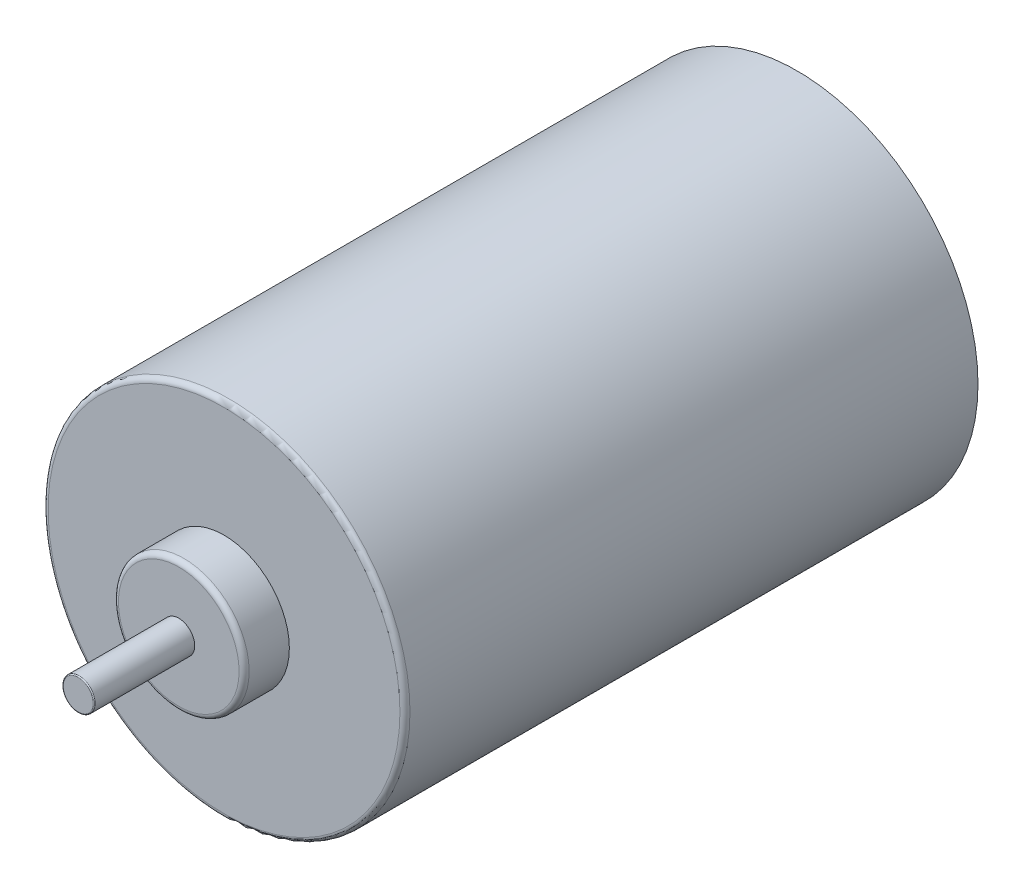
from build123d import *

# Parameters (mm, degrees)
SKETCH1_R                = 18
SKETCH1_R_2              = 17
BOSS_EXTRUDE1_DEPTH      = 57
SKETCH4_R                = 18
BOSS_EXTRUDE4_DEPTH      = 2
SKETCH5_R                = 13
BOSS_EXTRUDE5_DEPTH      = 2
SKETCH6_R                = 1.5875
CUT_EXTRUDE1_DEPTH       = 4
SKETCH7_R                = 18
BOSS_EXTRUDE6_DEPTH      = 1
SKETCH8_R                = 6.5
BOSS_EXTRUDE7_DEPTH      = 4.5
SKETCH9_R                = 1.5875
CUT_EXTRUDE4_DEPTH       = 64.5
SKETCH10_R               = 1.5875
BOSS_EXTRUDE8_DEPTH      = 10
BOSS_EXTRUDE8_DEPTH_BACK = 65
FILLET1_R                = 0.5
FILLET2_R                = 0.1
CHAMFER1_SIZE            = 1
FILLET3_R                = 0.1


with BuildPart() as part:
    # Sketch1 → Boss-Extrude1 (new body)
    with BuildSketch(Plane.XY):
        Circle(SKETCH1_R)
        Circle(SKETCH1_R_2, mode=Mode.SUBTRACT)
    extrude(amount=BOSS_EXTRUDE1_DEPTH)

    # Sketch4 → Boss-Extrude4 (add)
    with BuildSketch(Plane(origin=(0, 0, 0), x_dir=(-1, 0, 0), z_dir=(0, 0, -1))):
        Circle(SKETCH4_R)
    extrude(amount=-BOSS_EXTRUDE4_DEPTH)

    # Sketch5 → Boss-Extrude5 (add)
    with BuildSketch(Plane(origin=(0, 0, 0), x_dir=(-1, 0, 0), z_dir=(0, 0, -1))):
        Circle(SKETCH5_R)
    extrude(amount=BOSS_EXTRUDE5_DEPTH)

    # Sketch6 → Cut-Extrude1 (cut)
    with BuildSketch(Plane(origin=(0, 0, -2), x_dir=(-1, 0, 0), z_dir=(0, 0, -1))):
        Circle(SKETCH6_R)
    extrude(amount=-CUT_EXTRUDE1_DEPTH, mode=Mode.SUBTRACT)

    # Sketch7 → Boss-Extrude6 (add)
    with BuildSketch(Plane.XY.offset(57)):
        Circle(SKETCH7_R)
    extrude(amount=-BOSS_EXTRUDE6_DEPTH)

    # Sketch8 → Boss-Extrude7 (add)
    with BuildSketch(Plane.XY.offset(57)):
        Circle(SKETCH8_R)
    extrude(amount=BOSS_EXTRUDE7_DEPTH)

    # Sketch9 → Cut-Extrude4 (cut, through all)
    with BuildSketch(Plane.XY.offset(61.5)):
        Circle(SKETCH9_R)
    extrude(amount=-CUT_EXTRUDE4_DEPTH, mode=Mode.SUBTRACT)

    # Fillet1
    fillet1_edges = [part.edges().sort_by_distance(p)[0] for p in [
        (-6.5, 0, 61.5),
        (-18, 0, 57),
    ]]
    fillet(fillet1_edges, radius=FILLET1_R)

    # Chamfer1
    chamfer1_edges = [part.edges().sort_by_distance(p)[0] for p in [
        (13, 0, -2),
    ]]
    chamfer(chamfer1_edges, length=CHAMFER1_SIZE)


with BuildPart() as body_2:
    # Sketch10 → Boss-Extrude8 (new body, two sides)
    with BuildSketch(Plane.XY.offset(61.5)) as boss_extrude8_sk:
        Circle(SKETCH10_R)
    extrude(amount=BOSS_EXTRUDE8_DEPTH)
    extrude(boss_extrude8_sk.sketch, amount=-BOSS_EXTRUDE8_DEPTH_BACK)

    # Fillet2
    fillet2_edges = [body_2.edges().sort_by_distance(p)[0] for p in [
        (-1.5875, 0, 71.5),
    ]]
    fillet(fillet2_edges, radius=FILLET2_R)

    # Fillet3
    fillet3_edges = [body_2.edges().sort_by_distance(p)[0] for p in [
        (-1.5875, 0, -3.5),
    ]]
    fillet(fillet3_edges, radius=FILLET3_R)


solid = Compound([part.part, body_2.part])
